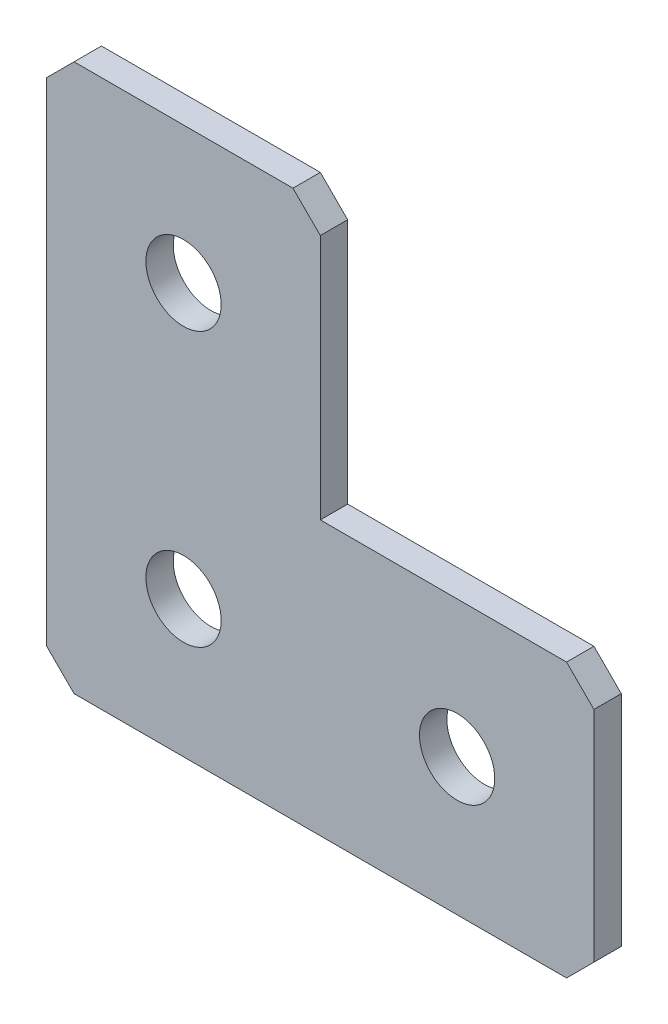
from build123d import *

# Parameters (mm, degrees)
EXTRUDE_1_DEPTH   = 2
HOLE_WIZARD_M51_D = 5.5
CHAMFER_1_SIZE    = 2


with BuildPart() as part:
    # Эскиз1 → Бобышка-Вытянуть1 (new body)
    with BuildSketch(Plane(origin=(0, 0, 0), x_dir=(1, 0, 0), z_dir=(0, 0, -1))):
        Polygon((0, 0), (0, 40), (40, 40), (40, 20), (20, 20), (20, 0), align=None)
    extrude(amount=EXTRUDE_1_DEPTH)

    # Отверстие с зазором M51 (through all)
    with Locations(Plane(origin=(0, 0, -2), x_dir=(1, 0, 0), z_dir=(0, 0, -1))):
        with Locations((10, 30), (10, 10), (30, 30)):
            Hole(HOLE_WIZARD_M51_D / 2)

    # Фаска1
    chamfer_1_edges = [part.edges().sort_by_distance(p)[0] for p in [
        (0, 0, -1),
        (0, -40, -1),
        (40, -40, -1),
        (40, -20, -1),
        (20, 0, -1),
    ]]
    chamfer(chamfer_1_edges, length=CHAMFER_1_SIZE)


solid = part.part
